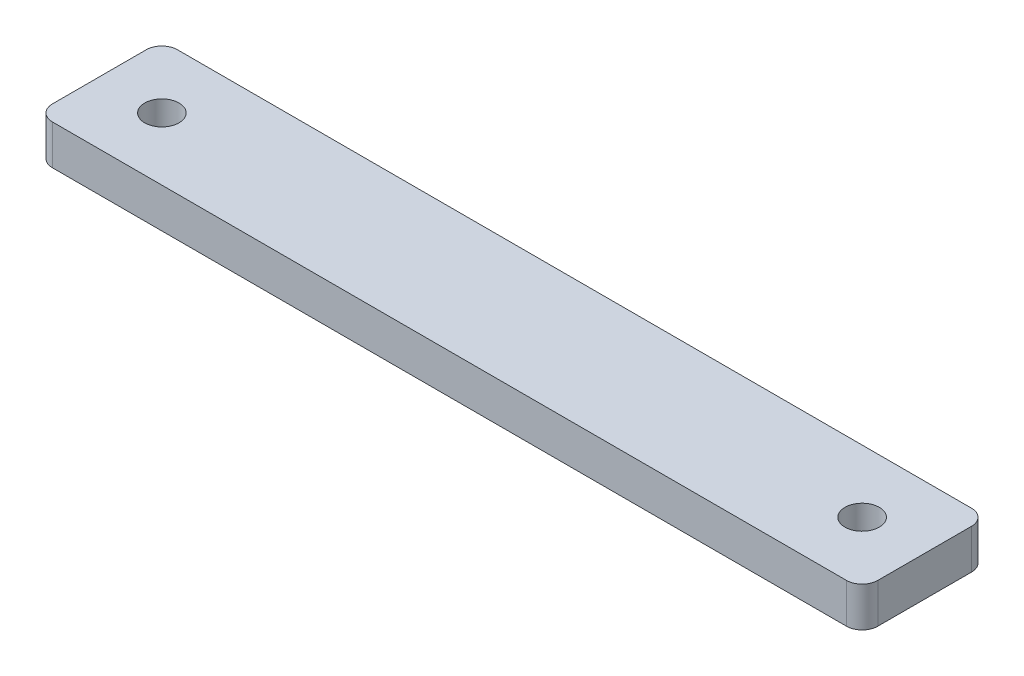
from build123d import *

# Parameters (mm, degrees)
SKETCH1_W           = 132
SKETCH1_H           = 20
SKETCH1_R           = 2.75
BOSS_EXTRUDE1_DEPTH = 6.35
FILLET1_R           = 2.5


with BuildPart() as part:
    # Sketch1 → Boss-Extrude1 (new body)
    with BuildSketch(Plane(origin=(0, 0, 0), x_dir=(1, 0, 0), z_dir=(0, 1, 0))):
        Rectangle(SKETCH1_W, SKETCH1_H)
        with Locations((-56, 0)):
            Circle(SKETCH1_R, mode=Mode.SUBTRACT)
        with Locations((56, 0)):
            Circle(SKETCH1_R, mode=Mode.SUBTRACT)
    extrude(amount=BOSS_EXTRUDE1_DEPTH)

    # Fillet1
    fillet1_edges = [part.edges().sort_by_distance(p)[0] for p in [
        (-66, 3.175, -10),
        (66, 3.175, -10),
        (66, 3.175, 10),
        (-66, 3.175, 10),
    ]]
    fillet(fillet1_edges, radius=FILLET1_R)


solid = part.part
